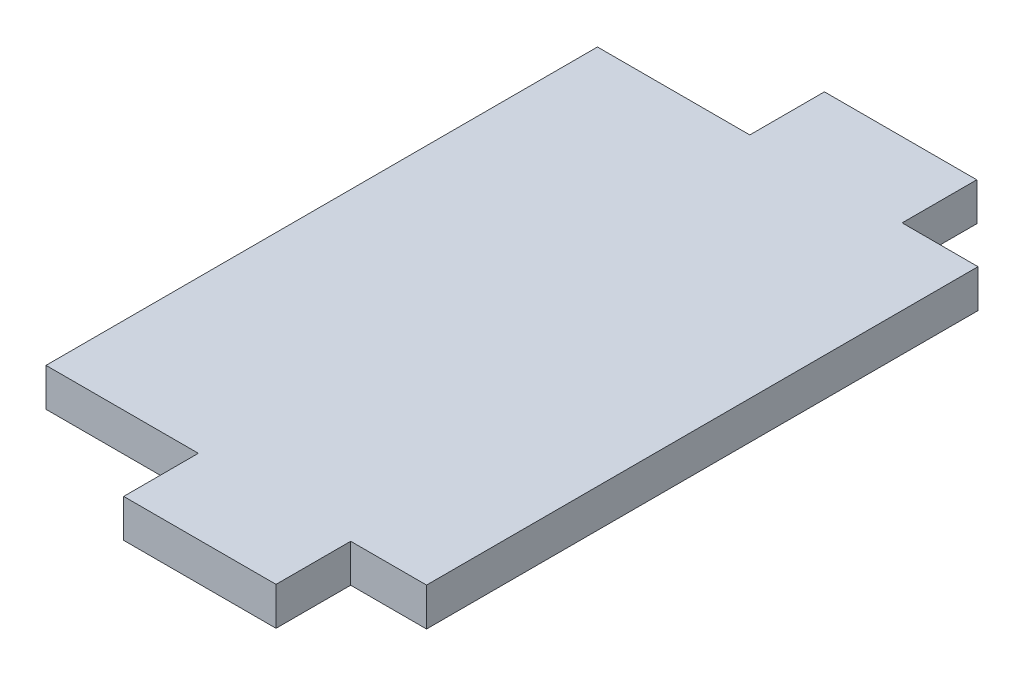
from build123d import *

# Parameters (mm, degrees)
BOSS_EXTRUDE1_DEPTH = 3.175


with BuildPart() as part:
    # Sketch1 → Boss-Extrude1 (new body)
    with BuildSketch(Plane(origin=(0, 0, 0), x_dir=(1, 0, 0), z_dir=(0, 1, 0))):
        Polygon((0, 0), (-12.7, 0), (-12.7, 6.223), (-25.4, 6.223), (-25.4, 52.197), (-12.7, 52.197), (-12.7, 58.42), (0, 58.42), (0, 52.197), (6.3246, 52.197), (6.3246, 6.223), (0, 6.223), align=None)
    extrude(amount=BOSS_EXTRUDE1_DEPTH)


solid = part.part
